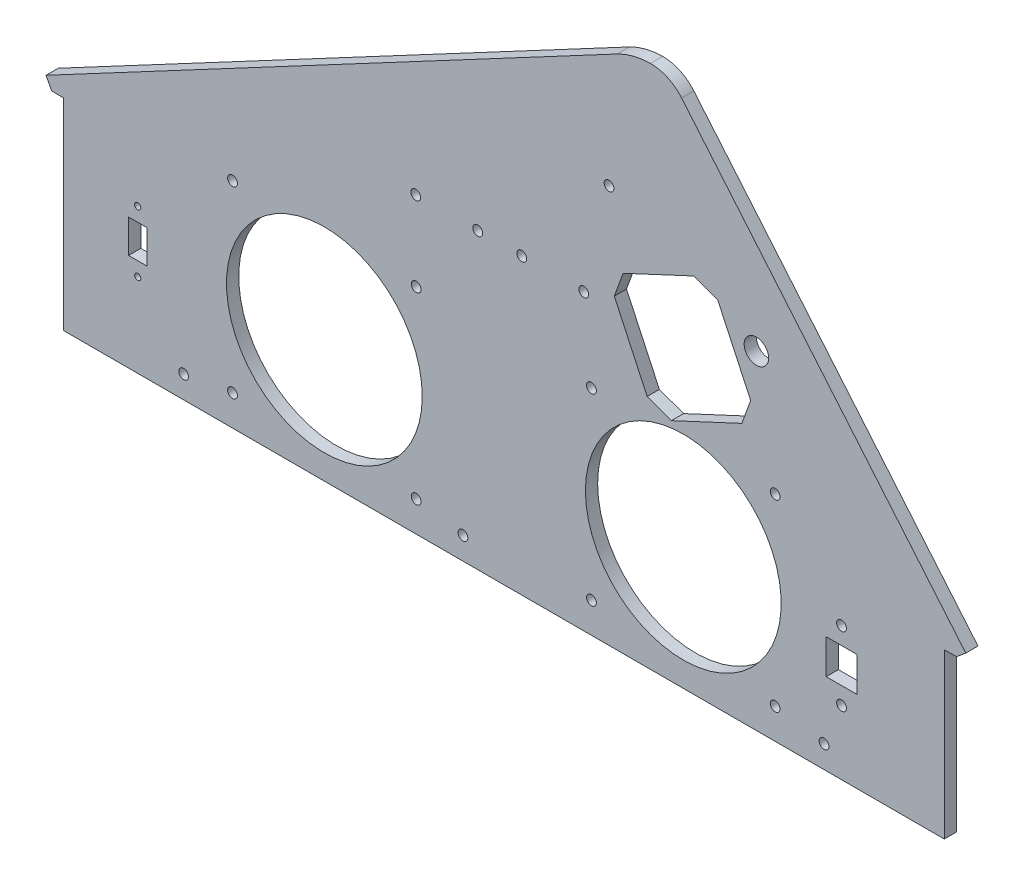
from build123d import *

# Parameters (mm, degrees)
BOSS_EXTRUDE1_DEPTH = 4.7625
SKETCH2_R           = 1.905
CUT_EXTRUDE1_DEPTH  = 407.344943003
SKETCH3_R           = 38.1
SKETCH3_R_2         = 1.905
CUT_EXTRUDE2_DEPTH  = 407.344943003
SKETCH4_R           = 1.905
SKETCH4_W           = 11.938
SKETCH4_H           = 13.462
CUT_EXTRUDE3_DEPTH  = 407.344943003
SKETCH5_R           = 1.905
CUT_EXTRUDE4_DEPTH  = 407.344943003
SKETCH6_R           = 1.1938
SKETCH6_W           = 7.112
SKETCH6_H           = 12.954
CUT_EXTRUDE5_DEPTH  = 407.344943003
SKETCH7_W           = 1.346153846
SKETCH7_H           = 0.358974359
CUT_EXTRUDE6_DEPTH  = 1.016
CUT_EXTRUDE7_DEPTH  = 407.344943141
SKETCH9_R           = 4.7625
CUT_EXTRUDE13_DEPTH = 579.055475551


with BuildPart() as part:
    # Sketch1 → Boss-Extrude1 (new body)
    with BuildSketch(Plane.XY):
        with BuildLine():
            Line((342.9, 0), (342.9, 63.846084025))
            Line((342.9, 63.846084025), (347.6625, 63.846084025))
            Line((347.6625, 63.846084025), (351.246350093, 66.853291317))
            Line((351.246350093, 66.853291317), (240.642270942, 198.6661))
            ThreePointArc((240.642270942, 198.6661), (235.199196057, 202.821062746), (228.502863126, 204.252811641))
            ThreePointArc((228.502863126, 204.252811641), (221.829642318, 203.38166914), (215.553659607, 200.9521))
            Line((215.553659607, 200.9521), (-6.746192899, 82.628723888))
            Line((-6.746192899, 82.628723888), (-4.5085, 78.424661955))
            Line((-4.5085, 78.424661955), (0, 78.424661955))
            Line((0, 78.424661955), (0, 0))
            Line((0, 0), (342.9, 0))
        make_face()
    extrude(amount=BOSS_EXTRUDE1_DEPTH)

    # Sketch2 → Cut-Extrude1 (cut, through all)
    with BuildSketch(Plane.XY.offset(4.7625)):
        with Locations((46.8249, 8.73125)):
            Circle(SKETCH2_R)
        with Locations((296.0751, 8.73125)):
            Circle(SKETCH2_R)
        with Locations((155.5496, 8.73125)):
            Circle(SKETCH2_R)
        with Locations((212.41385, 154.94)):
            Circle(SKETCH2_R)
    extrude(amount=-CUT_EXTRUDE1_DEPTH, mode=Mode.SUBTRACT)

    # Sketch3 → Cut-Extrude2 (cut, through all)
    with BuildSketch(Plane.XY.offset(4.7625)):
        with Locations((101.6, 47.625)):
            Circle(SKETCH3_R)
        with Locations((137.35, 83.375)):
            Circle(SKETCH3_R_2)
        with Locations((65.85, 83.375)):
            Circle(SKETCH3_R_2)
        with Locations((65.85, 11.875)):
            Circle(SKETCH3_R_2)
        with Locations((137.35, 11.875)):
            Circle(SKETCH3_R_2)
        with Locations((205.55, 11.875)):
            Circle(SKETCH3_R_2)
        with Locations((277.05, 11.875)):
            Circle(SKETCH3_R_2)
        with Locations((277.05, 83.375)):
            Circle(SKETCH3_R_2)
        with Locations((205.55, 83.375)):
            Circle(SKETCH3_R_2)
        with Locations((241.3, 47.625)):
            Circle(SKETCH3_R)
    extrude(amount=-CUT_EXTRUDE2_DEPTH, mode=Mode.SUBTRACT)

    # Sketch4 → Cut-Extrude3 (cut, through all)
    with BuildSketch(Plane.XY.offset(4.7625)):
        with Locations((302.895, 51.943)):
            Circle(SKETCH4_R)
        with Locations((302.895, 25.019)):
            Circle(SKETCH4_R)
        with Locations((302.895, 38.481)):
            Rectangle(SKETCH4_W, SKETCH4_H)
    extrude(amount=-CUT_EXTRUDE3_DEPTH, mode=Mode.SUBTRACT)

    # Sketch5 → Cut-Extrude4 (cut, through all)
    with BuildSketch(Plane.XY.offset(4.7625)):
        with Locations((137.16, 114.3)):
            Circle(SKETCH5_R)
        with Locations((161.29, 114.3)):
            Circle(SKETCH5_R)
        with Locations((178.435, 114.3)):
            Circle(SKETCH5_R)
        with Locations((202.565, 114.3)):
            Circle(SKETCH5_R)
    extrude(amount=-CUT_EXTRUDE4_DEPTH, mode=Mode.SUBTRACT)

    # Sketch6 → Cut-Extrude5 (cut, through all)
    with BuildSketch(Plane.XY.offset(4.7625)):
        with Locations((28.956, 56.35)):
            Circle(SKETCH6_R)
        with Locations((28.956, 32.55)):
            Circle(SKETCH6_R)
        with Locations((28.956, 44.45)):
            Rectangle(SKETCH6_W, SKETCH6_H)
    extrude(amount=-CUT_EXTRUDE5_DEPTH, mode=Mode.SUBTRACT)

    # Sketch7 → Cut-Extrude6 (cut)
    # profile 1 of 9: a face of its own
    with BuildSketch(Plane(origin=(0, 0, 0), x_dir=(-1, 0, 0), z_dir=(0, 0, -1))):
        with BuildLine():
            Line((-20.262820513, 9.93974359), (-20.020933494, 9.749739583))
            Line((-20.020933494, 9.749739583), (-20.945713141, 8.335576923))
            add(Edge.make_bspline(
                [(-20.945713141, 8.335576923), (-20.884142864, 8.345390784), (-20.764043077, 8.364533829), (-20.642477179, 8.367691774), (-20.583233173, 8.369230769)],
                knots=[0, 0, 0, 0, 1.025318673, 2, 2, 2, 2], degree=3))
            add(Edge.make_bspline(
                [(-20.583233173, 8.369230769), (-20.547660677, 8.368274658), (-20.477637276, 8.36639258), (-20.374830474, 8.351908729), (-20.276041538, 8.329083617), (-20.181679926, 8.295811362), (-20.091406944, 8.253309007), (-20.004704548, 8.202370137), (-19.923202538, 8.140364457), (-19.845851359, 8.071099501), (-19.775624261, 7.994382516), (-19.713448206, 7.91298118), (-19.661221414, 7.826980299), (-19.618847492, 7.736423433), (-19.585942614, 7.641450173), (-19.561954969, 7.542182034), (-19.547775376, 7.438550562), (-19.545849885, 7.368072387), (-19.544871795, 7.332271635)],
                knots=[0, 0, 0, 0, 1.04369286, 2.054478336, 3.041073146, 4.015093852, 4.984733326, 5.965804835, 6.960378782, 7.985147595, 9.009457201, 10.008161701, 10.986880575, 11.956520048, 12.937015923, 13.931873656, 14.949455224, 16, 16, 16, 16], degree=3))
            add(Edge.make_bspline(
                [(-19.544871795, 7.332271635), (-19.5462949, 7.283291931), (-19.549095233, 7.186911465), (-19.576999029, 7.046534758), (-19.620358674, 6.912802243), (-19.682336203, 6.787849071), (-19.759318586, 6.671846502), (-19.853196178, 6.569061036), (-19.960639667, 6.477390999), (-20.082126465, 6.40073438), (-20.212869429, 6.338131329), (-20.350221426, 6.293166087), (-20.492848573, 6.265482617), (-20.589653181, 6.262012015), (-20.638621795, 6.26025641)],
                knots=[0, 0, 0, 0, 1.031375318, 2.029502543, 3.004789286, 3.987476834, 4.960371455, 5.9300674, 6.912260825, 7.929083631, 8.949397511, 9.960523116, 10.96833055, 12, 12, 12, 12], degree=3))
            add(Edge.make_bspline(
                [(-20.638621795, 6.26025641), (-20.685718496, 6.261784616), (-20.779008814, 6.264811724), (-20.916241608, 6.291777662), (-21.048104625, 6.335484765), (-21.173674006, 6.395699043), (-21.289994619, 6.471756926), (-21.394060255, 6.563319205), (-21.48535203, 6.66842867), (-21.561326651, 6.787069018), (-21.621585383, 6.914558975), (-21.666775308, 7.047496132), (-21.693171551, 7.185396113), (-21.696860108, 7.278877252), (-21.698717949, 7.325961538)],
                knots=[0, 0, 0, 0, 1.012016664, 2.004627821, 2.994792927, 3.992885782, 4.990978636, 5.973936114, 6.964471063, 7.975201453, 8.993600317, 9.990122807, 10.98767138, 12, 12, 12, 12], degree=3))
            add(Edge.make_bspline(
                [(-21.698717949, 7.325961538), (-21.697536504, 7.362006122), (-21.695124219, 7.435602274), (-21.678280828, 7.547066302), (-21.651216034, 7.661117383), (-21.620905787, 7.757871577), (-21.588880177, 7.837133099), (-21.562227638, 7.90103659), (-21.529053642, 7.966797663), (-21.49368026, 8.036671299), (-21.452923391, 8.108856731), (-21.408607742, 8.184560401), (-21.359508091, 8.262578329), (-21.325087928, 8.315522524), (-21.307491987, 8.342588141)],
                knots=[0, 0, 0, 0, 1.173818275, 2.396712641, 3.66331629, 4.989737886, 5.693666774, 6.447286557, 7.243889047, 8.091586357, 8.998013824, 9.943181721, 10.948533338, 12, 12, 12, 12], degree=3))
            Line((-21.307491987, 8.342588141), (-20.262820513, 9.93974359))
        make_face()
        with BuildLine():
            add(Edge.make_bspline(
                [(-20.649138622, 8.01025641), (-20.675800867, 8.009478367), (-20.727879976, 8.007958621), (-20.804287391, 7.999133369), (-20.876600642, 7.982514304), (-20.945777776, 7.961347972), (-21.010525479, 7.932244912), (-21.071314319, 7.896893113), (-21.12837937, 7.855271935), (-21.181122922, 7.807971024), (-21.228942586, 7.756182991), (-21.270123716, 7.700713469), (-21.305646116, 7.642899266), (-21.334527935, 7.582257323), (-21.357018011, 7.518810824), (-21.373286262, 7.452851574), (-21.382340013, 7.383937268), (-21.383846245, 7.337204766), (-21.384615385, 7.313341346)],
                knots=[0, 0, 0, 0, 1.129588631, 2.206414736, 3.251139165, 4.268635594, 5.265702196, 6.250456724, 7.242448911, 8.251968645, 9.246821453, 10.222880186, 11.173611482, 12.116736599, 13.062300278, 14.020270554, 14.989073742, 16, 16, 16, 16], degree=3))
            add(Edge.make_bspline(
                [(-21.384615385, 7.313341346), (-21.383989023, 7.289691366), (-21.382760822, 7.243317277), (-21.371608502, 7.174978097), (-21.354573419, 7.109213189), (-21.329233023, 7.04636159), (-21.299006135, 6.985465272), (-21.259100811, 6.928729986), (-21.214884025, 6.872709916), (-21.162030092, 6.821708445), (-21.105306729, 6.774251821), (-21.044705526, 6.732771567), (-20.981545566, 6.697285394), (-20.914974144, 6.669474296), (-20.84593576, 6.646650009), (-20.773855206, 6.63058853), (-20.698682351, 6.621508004), (-20.647760413, 6.61999981), (-20.621794872, 6.619230769)],
                knots=[0, 0, 0, 0, 0.989467248, 1.94019797, 2.891935182, 3.827694429, 4.772920941, 5.730924762, 6.725747692, 7.756678648, 8.79901574, 9.819492441, 10.826891316, 11.826466727, 12.835195252, 13.867842842, 14.912794438, 16, 16, 16, 16], degree=3))
            add(Edge.make_bspline(
                [(-20.621794872, 6.619230769), (-20.595829373, 6.619999871), (-20.544907519, 6.621508182), (-20.469734058, 6.630587851), (-20.39765574, 6.646652499), (-20.328609231, 6.66946527), (-20.2620678, 6.697318879), (-20.198963079, 6.732550799), (-20.138934985, 6.774506917), (-20.082174386, 6.821627345), (-20.029540447, 6.873000197), (-19.984263168, 6.928229919), (-19.945579935, 6.985923815), (-19.914145748, 7.046121704), (-19.889084457, 7.109251192), (-19.87196299, 7.174967916), (-19.860833701, 7.243319942), (-19.859602334, 7.289692266), (-19.858974359, 7.313341346)],
                knots=[0, 0, 0, 0, 1.087397944, 2.132534446, 3.165364764, 4.174271784, 5.174024072, 6.181601208, 7.194203697, 8.236725232, 9.267838612, 10.269026844, 11.221737037, 12.171628256, 13.107553087, 14.05945871, 15.010357665, 16, 16, 16, 16], degree=3))
            add(Edge.make_bspline(
                [(-19.858974359, 7.313341346), (-19.859524652, 7.337235897), (-19.860604698, 7.38413313), (-19.872820647, 7.452820748), (-19.889763021, 7.519145954), (-19.915346051, 7.582691903), (-19.948582596, 7.64320783), (-19.989066003, 7.700999431), (-20.035898573, 7.756509779), (-20.089996113, 7.808072587), (-20.148886347, 7.855219665), (-20.211501932, 7.896839221), (-20.277009906, 7.931964198), (-20.345343848, 7.9612713), (-20.417286731, 7.982420774), (-20.49167707, 7.999074017), (-20.569466313, 8.007936035), (-20.622242921, 8.0094731), (-20.649138622, 8.01025641)],
                knots=[0, 0, 0, 0, 0.978206639, 1.919901502, 2.851605144, 3.780102724, 4.718870031, 5.675451981, 6.667674623, 7.690630536, 8.733308323, 9.756129687, 10.767539656, 11.776269907, 12.797430371, 13.836405707, 14.897401972, 16, 16, 16, 16], degree=3))
        make_face(mode=Mode.SUBTRACT)
    # profile 2 of 9: a face of its own
    with BuildSketch(Plane(origin=(0, 0, 0), x_dir=(-1, 0, 0), z_dir=(0, 0, -1))):
        with BuildLine():
            add(Edge.make_bspline(
                [(-24.570512821, 8.098597756), (-24.570184802, 8.154695144), (-24.569547622, 8.263665128), (-24.562459201, 8.42244977), (-24.550683859, 8.571410059), (-24.534546486, 8.710553125), (-24.514908506, 8.83991489), (-24.488693019, 8.959149647), (-24.458880217, 9.068809254), (-24.424327771, 9.169251302), (-24.385339982, 9.261829005), (-24.342905721, 9.348254207), (-24.295340927, 9.428396139), (-24.245364014, 9.503533929), (-24.190951942, 9.572437624), (-24.133653152, 9.636080287), (-24.071231276, 9.692991037), (-24.005808267, 9.744837339), (-23.936791803, 9.790286811), (-23.866149137, 9.83031955), (-23.793394031, 9.864519417), (-23.718327848, 9.891409853), (-23.64162529, 9.9136207), (-23.563018223, 9.928809647), (-23.482376859, 9.938366556), (-23.427945425, 9.939280224), (-23.400340545, 9.93974359)],
                knots=[0, 0, 0, 0, 1.646270934, 3.197905019, 4.663502075, 6.030701355, 7.308322542, 8.50163776, 9.611534131, 10.641858119, 11.616356847, 12.558055219, 13.465016945, 14.349605745, 15.204443733, 16.039544428, 16.859896111, 17.680448484, 18.487036065, 19.28249412, 20.06191084, 20.843045899, 21.620316918, 22.403196591, 23.190181807, 24, 24, 24, 24], degree=3))
            add(Edge.make_bspline(
                [(-23.400340545, 9.93974359), (-23.372505066, 9.939255775), (-23.317149057, 9.938285664), (-23.235308682, 9.928961721), (-23.155359001, 9.913490598), (-23.077640862, 9.891569623), (-23.001515875, 9.864373947), (-22.927579468, 9.83028683), (-22.855372386, 9.790607962), (-22.786042099, 9.743984085), (-22.718827483, 9.692001809), (-22.65537952, 9.63323914), (-22.595692434, 9.568289421), (-22.539017129, 9.497847557), (-22.486961532, 9.420562472), (-22.4373881, 9.337778362), (-22.393016064, 9.248047497), (-22.350281388, 9.15286703), (-22.313394402, 9.049603371), (-22.280128156, 8.93883861), (-22.253249188, 8.819264423), (-22.230859916, 8.691508178), (-22.21351502, 8.555100695), (-22.200882377, 8.410334379), (-22.194209292, 8.257113989), (-22.192952591, 8.15235614), (-22.192307692, 8.098597756)],
                knots=[0, 0, 0, 0, 0.810914788, 1.612654377, 2.396697861, 3.181598691, 3.963628158, 4.749916497, 5.551656086, 6.361998678, 7.18212741, 8.025565596, 8.878627764, 9.750805457, 10.657531673, 11.591944965, 12.560506719, 13.57287815, 14.630710178, 15.753379473, 16.941251878, 18.199788006, 19.531962791, 20.947069417, 22.433333509, 24, 24, 24, 24], degree=3))
            add(Edge.make_bspline(
                [(-22.192307692, 8.098597756), (-22.192959277, 8.045073848), (-22.194228863, 7.940784697), (-22.20080757, 7.788253721), (-22.213766201, 7.644255678), (-22.229976189, 7.508445216), (-22.252427152, 7.381387597), (-22.280032318, 7.262643148), (-22.310682641, 7.151699077), (-22.348517435, 7.049464265), (-22.389928146, 6.954512542), (-22.434983342, 6.865845394), (-22.483253168, 6.782679101), (-22.535841913, 6.705679354), (-22.591895326, 6.634300697), (-22.652613115, 6.569803074), (-22.7162837, 6.510632402), (-22.783696116, 6.457980775), (-22.854107667, 6.41189597), (-22.926066744, 6.37068212), (-23.000850127, 6.337449425), (-23.07676308, 6.308914384), (-23.154891446, 6.287113932), (-23.235137837, 6.272040077), (-23.317094073, 6.261468228), (-23.372495638, 6.260661748), (-23.400340545, 6.26025641)],
                knots=[0, 0, 0, 0, 1.561518951, 3.042555995, 4.452378317, 5.7783523, 7.031515105, 8.214008947, 9.334062868, 10.386615937, 11.391082383, 12.354592575, 13.286541444, 14.194233754, 15.072674879, 15.931287219, 16.775624067, 17.606195743, 18.42308326, 19.229000347, 20.022332153, 20.807536673, 21.593273796, 22.3848459, 23.188221202, 24, 24, 24, 24], degree=3))
            add(Edge.make_bspline(
                [(-23.400340545, 6.26025641), (-23.427944659, 6.260722766), (-23.482374584, 6.261642328), (-23.563027009, 6.271156059), (-23.641309453, 6.286451562), (-23.717608207, 6.307868166), (-23.792314722, 6.334083003), (-23.864411008, 6.368236686), (-23.934698692, 6.407570755), (-24.002990248, 6.452366177), (-24.068002409, 6.50368786), (-24.130101014, 6.560452149), (-24.187726033, 6.62407556), (-24.241360129, 6.693553483), (-24.292334217, 6.768246725), (-24.339223591, 6.849175098), (-24.382594445, 6.936017709), (-24.422237935, 7.02933562), (-24.457386599, 7.130490547), (-24.488434307, 7.240639726), (-24.512948464, 7.360755362), (-24.53393142, 7.489872729), (-24.550855803, 7.628546659), (-24.562410128, 7.776852438), (-24.569551443, 7.934697647), (-24.570186514, 8.042967421), (-24.570512821, 8.098597756)],
                knots=[0, 0, 0, 0, 0.810891512, 1.598919785, 2.382837074, 3.152667961, 3.926044502, 4.706494248, 5.493654104, 6.291793342, 7.103789334, 7.925228297, 8.761435821, 9.622817696, 10.50288917, 11.416980706, 12.369136599, 13.353924996, 14.394355917, 15.514179734, 16.714354668, 17.994756427, 19.357759367, 20.818452758, 22.365282078, 24, 24, 24, 24], degree=3))
        make_face()
        with BuildLine():
            add(Edge.make_bspline(
                [(-24.256410256, 8.1), (-24.256290809, 8.053251301), (-24.256058986, 7.962521256), (-24.250002785, 7.830677995), (-24.241752553, 7.707707667), (-24.231111256, 7.59345413), (-24.215308308, 7.488304118), (-24.19760152, 7.391534435), (-24.17605343, 7.303657197), (-24.150558412, 7.224069387), (-24.121519316, 7.151420318), (-24.089813452, 7.083819103), (-24.055752729, 7.020467167), (-24.017633578, 6.961933558), (-23.976118515, 6.908027394), (-23.932145256, 6.857794562), (-23.884072672, 6.812997581), (-23.817568929, 6.759270726), (-23.729772455, 6.703751592), (-23.619152, 6.655405502), (-23.505483549, 6.625023046), (-23.428332299, 6.62115929), (-23.389823718, 6.619230769)],
                knots=[0, 0, 0, 0, 1.459021318, 2.831673884, 4.118529203, 5.306027144, 6.411944654, 7.436330062, 8.375795394, 9.233974572, 10.042671642, 10.816086306, 11.563610507, 12.285937304, 12.993564865, 13.685989202, 14.367179055, 15.041617293, 16.353048772, 17.594441528, 18.799311195, 20, 20, 20, 20], degree=3))
            add(Edge.make_bspline(
                [(-23.389823718, 6.619230769), (-23.351066046, 6.62082855), (-23.273630723, 6.624020813), (-23.160496928, 6.65481955), (-23.050666658, 6.70128909), (-22.964594718, 6.756236595), (-22.899112174, 6.808564925), (-22.852195184, 6.853179573), (-22.809133136, 6.90313544), (-22.768291061, 6.957034736), (-22.730831985, 7.01590722), (-22.696768847, 7.079469796), (-22.6656855, 7.147898973), (-22.647976454, 7.195668713), (-22.638922276, 7.220092147)],
                knots=[0, 0, 0, 0, 1.353760809, 2.704726607, 4.075137775, 5.516104923, 6.260822281, 7.007110065, 7.778089737, 8.566572457, 9.372053459, 10.217411131, 11.088608312, 12, 12, 12, 12], degree=3))
            add(Edge.make_bspline(
                [(-22.638922276, 7.220092147), (-22.628370508, 7.251321887), (-22.606945894, 7.314731651), (-22.57933412, 7.413095303), (-22.557588721, 7.516298067), (-22.538025355, 7.623723184), (-22.524672299, 7.736162885), (-22.513924486, 7.853269269), (-22.507593799, 7.975130631), (-22.506809048, 8.057925622), (-22.506410256, 8.1)],
                knots=[0, 0, 0, 0, 0.884706709, 1.796334032, 2.740027952, 3.714592787, 4.726048262, 5.777819803, 6.87074269, 8, 8, 8, 8], degree=3))
            add(Edge.make_bspline(
                [(-22.506410256, 8.1), (-22.506960446, 8.142067573), (-22.508036733, 8.224360737), (-22.512150721, 8.344878918), (-22.522774296, 8.459346679), (-22.534573414, 8.568257152), (-22.551970636, 8.671007454), (-22.570728442, 8.768457759), (-22.595929655, 8.859400784), (-22.62284943, 8.945260366), (-22.653659825, 9.025061021), (-22.687575559, 9.099174807), (-22.723797318, 9.167959532), (-22.763139559, 9.231226473), (-22.805135242, 9.289259016), (-22.850892791, 9.340893611), (-22.898597164, 9.387730579), (-22.96541435, 9.441193148), (-23.052888639, 9.495704843), (-23.161734287, 9.545870603), (-23.275004931, 9.574678896), (-23.351578385, 9.578740583), (-23.389823718, 9.580769231)],
                knots=[0, 0, 0, 0, 1.31362396, 2.569729283, 3.763502607, 4.902122613, 5.988968491, 7.01645872, 7.998833611, 8.933434873, 9.825090667, 10.667526885, 11.477055099, 12.250526234, 12.991942729, 13.710640831, 14.402115721, 15.076753259, 16.378508321, 17.609869233, 18.806226677, 20, 20, 20, 20], degree=3))
            add(Edge.make_bspline(
                [(-23.389823718, 9.580769231), (-23.42853431, 9.578737784), (-23.506026016, 9.57467119), (-23.62047397, 9.545977936), (-23.730178322, 9.49596497), (-23.817421297, 9.441012598), (-23.884285083, 9.388674287), (-23.931367777, 9.343287833), (-23.975513949, 9.293641578), (-24.016181649, 9.239239663), (-24.054270932, 9.180774296), (-24.089251945, 9.117785531), (-24.120769274, 9.049954167), (-24.149853811, 8.977337732), (-24.175426599, 8.897756787), (-24.196520562, 8.809987794), (-24.216007615, 8.713525902), (-24.229802884, 8.607806394), (-24.24206664, 8.49352424), (-24.249947988, 8.370246922), (-24.256079245, 8.238182542), (-24.256297709, 8.146983383), (-24.256410256, 8.1)],
                knots=[0, 0, 0, 0, 1.207732386, 2.417664972, 3.655092373, 4.956220595, 5.625982001, 6.301752483, 6.994047911, 7.697131622, 8.419323945, 9.170223765, 9.943494443, 10.752040957, 11.610060368, 12.549350801, 13.567764191, 14.679664412, 15.874934091, 17.154273443, 18.533957287, 20, 20, 20, 20], degree=3))
        make_face(mode=Mode.SUBTRACT)
    # profile 3 of 9: a face of its own
    with BuildSketch(Plane(origin=(0, 0, 0), x_dir=(-1, 0, 0), z_dir=(0, 0, -1))):
        with BuildLine():
            Line((-25.647435897, 9.93974359), (-25.405548878, 9.749739583))
            Line((-25.405548878, 9.749739583), (-26.330328526, 8.335576923))
            add(Edge.make_bspline(
                [(-26.330328526, 8.335576923), (-26.268758249, 8.345390784), (-26.148658462, 8.364533829), (-26.027092563, 8.367691774), (-25.967848558, 8.369230769)],
                knots=[0, 0, 0, 0, 1.025318673, 2, 2, 2, 2], degree=3))
            add(Edge.make_bspline(
                [(-25.967848558, 8.369230769), (-25.932276061, 8.368274658), (-25.862252661, 8.36639258), (-25.759445859, 8.351908729), (-25.660656923, 8.329083617), (-25.56629531, 8.295811362), (-25.476022329, 8.253309007), (-25.389319933, 8.202370137), (-25.307817922, 8.140364457), (-25.230466743, 8.071099501), (-25.160239646, 7.994382516), (-25.09806359, 7.91298118), (-25.045836799, 7.826980299), (-25.003462877, 7.736423433), (-24.970557998, 7.641450173), (-24.946570353, 7.542182034), (-24.93239076, 7.438550562), (-24.93046527, 7.368072387), (-24.929487179, 7.332271635)],
                knots=[0, 0, 0, 0, 1.04369286, 2.054478336, 3.041073146, 4.015093852, 4.984733326, 5.965804835, 6.960378782, 7.985147595, 9.009457201, 10.008161701, 10.986880575, 11.956520048, 12.937015923, 13.931873656, 14.949455224, 16, 16, 16, 16], degree=3))
            add(Edge.make_bspline(
                [(-24.929487179, 7.332271635), (-24.930910284, 7.283291931), (-24.933710618, 7.186911465), (-24.961614414, 7.046534758), (-25.004974059, 6.912802243), (-25.066951587, 6.787849071), (-25.14393397, 6.671846502), (-25.237811563, 6.569061036), (-25.345255051, 6.477390999), (-25.466741849, 6.40073438), (-25.597484813, 6.338131329), (-25.734836811, 6.293166087), (-25.877463957, 6.265482617), (-25.974268565, 6.262012015), (-26.023237179, 6.26025641)],
                knots=[0, 0, 0, 0, 1.031375318, 2.029502543, 3.004789286, 3.987476834, 4.960371455, 5.9300674, 6.912260825, 7.929083631, 8.949397511, 9.960523116, 10.96833055, 12, 12, 12, 12], degree=3))
            add(Edge.make_bspline(
                [(-26.023237179, 6.26025641), (-26.07033388, 6.261784616), (-26.163624198, 6.264811724), (-26.300856992, 6.291777662), (-26.43272001, 6.335484765), (-26.558289391, 6.395699043), (-26.674610004, 6.471756926), (-26.77867564, 6.563319205), (-26.869967415, 6.66842867), (-26.945942035, 6.787069018), (-27.006200767, 6.914558975), (-27.051390693, 7.047496132), (-27.077786936, 7.185396113), (-27.081475493, 7.278877252), (-27.083333333, 7.325961538)],
                knots=[0, 0, 0, 0, 1.012016664, 2.004627821, 2.994792927, 3.992885782, 4.990978636, 5.973936114, 6.964471063, 7.975201453, 8.993600317, 9.990122807, 10.98767138, 12, 12, 12, 12], degree=3))
            add(Edge.make_bspline(
                [(-27.083333333, 7.325961538), (-27.082151888, 7.362006122), (-27.079739603, 7.435602274), (-27.062896213, 7.547066302), (-27.035831418, 7.661117383), (-27.005521172, 7.757871577), (-26.973495562, 7.837133099), (-26.946843022, 7.90103659), (-26.913669026, 7.966797663), (-26.878295645, 8.036671299), (-26.837538776, 8.108856731), (-26.793223127, 8.184560401), (-26.744123476, 8.262578329), (-26.709703313, 8.315522524), (-26.692107372, 8.342588141)],
                knots=[0, 0, 0, 0, 1.173818275, 2.396712641, 3.66331629, 4.989737886, 5.693666774, 6.447286557, 7.243889047, 8.091586357, 8.998013824, 9.943181721, 10.948533338, 12, 12, 12, 12], degree=3))
            Line((-26.692107372, 8.342588141), (-25.647435897, 9.93974359))
        make_face()
        with BuildLine():
            add(Edge.make_bspline(
                [(-26.033754006, 8.01025641), (-26.060416251, 8.009478367), (-26.112495361, 8.007958621), (-26.188902775, 7.999133369), (-26.261216027, 7.982514304), (-26.33039316, 7.961347972), (-26.395140863, 7.932244912), (-26.455929703, 7.896893113), (-26.512994755, 7.855271935), (-26.565738307, 7.807971024), (-26.61355797, 7.756182991), (-26.654739101, 7.700713469), (-26.690261501, 7.642899266), (-26.71914332, 7.582257323), (-26.741633396, 7.518810824), (-26.757901647, 7.452851574), (-26.766955398, 7.383937268), (-26.768461629, 7.337204766), (-26.769230769, 7.313341346)],
                knots=[0, 0, 0, 0, 1.129588631, 2.206414736, 3.251139165, 4.268635594, 5.265702196, 6.250456724, 7.242448911, 8.251968645, 9.246821453, 10.222880186, 11.173611482, 12.116736599, 13.062300278, 14.020270554, 14.989073742, 16, 16, 16, 16], degree=3))
            add(Edge.make_bspline(
                [(-26.769230769, 7.313341346), (-26.768604408, 7.289691366), (-26.767376206, 7.243317277), (-26.756223886, 7.174978097), (-26.739188804, 7.109213189), (-26.713848408, 7.04636159), (-26.68362152, 6.985465272), (-26.643716196, 6.928729986), (-26.59949941, 6.872709916), (-26.546645476, 6.821708445), (-26.489922113, 6.774251821), (-26.429320911, 6.732771567), (-26.366160951, 6.697285394), (-26.299589529, 6.669474296), (-26.230551145, 6.646650009), (-26.158470591, 6.63058853), (-26.083297735, 6.621508004), (-26.032375797, 6.61999981), (-26.006410256, 6.619230769)],
                knots=[0, 0, 0, 0, 0.989467248, 1.94019797, 2.891935182, 3.827694429, 4.772920941, 5.730924762, 6.725747692, 7.756678648, 8.79901574, 9.819492441, 10.826891316, 11.826466727, 12.835195252, 13.867842842, 14.912794438, 16, 16, 16, 16], degree=3))
            add(Edge.make_bspline(
                [(-26.006410256, 6.619230769), (-25.980444758, 6.619999871), (-25.929522903, 6.621508182), (-25.854349443, 6.630587851), (-25.782271124, 6.646652499), (-25.713224616, 6.66946527), (-25.646683185, 6.697318879), (-25.583578463, 6.732550799), (-25.52355037, 6.774506917), (-25.46678977, 6.821627345), (-25.414155832, 6.873000197), (-25.368878553, 6.928229919), (-25.33019532, 6.985923815), (-25.298761133, 7.046121704), (-25.273699841, 7.109251192), (-25.256578374, 7.174967916), (-25.245449085, 7.243319942), (-25.244217719, 7.289692266), (-25.243589744, 7.313341346)],
                knots=[0, 0, 0, 0, 1.087397944, 2.132534446, 3.165364764, 4.174271784, 5.174024072, 6.181601208, 7.194203697, 8.236725232, 9.267838612, 10.269026844, 11.221737037, 12.171628256, 13.107553087, 14.05945871, 15.010357665, 16, 16, 16, 16], degree=3))
            add(Edge.make_bspline(
                [(-25.243589744, 7.313341346), (-25.244140037, 7.337235897), (-25.245220083, 7.38413313), (-25.257436031, 7.452820748), (-25.274378405, 7.519145954), (-25.299961436, 7.582691903), (-25.333197981, 7.64320783), (-25.373681388, 7.700999431), (-25.420513958, 7.756509779), (-25.474611498, 7.808072587), (-25.533501732, 7.855219665), (-25.596117317, 7.896839221), (-25.661625291, 7.931964198), (-25.729959233, 7.9612713), (-25.801902116, 7.982420774), (-25.876292455, 7.999074017), (-25.954081698, 8.007936035), (-26.006858306, 8.0094731), (-26.033754006, 8.01025641)],
                knots=[0, 0, 0, 0, 0.978206639, 1.919901502, 2.851605144, 3.780102724, 4.718870031, 5.675451981, 6.667674623, 7.690630536, 8.733308323, 9.756129687, 10.767539656, 11.776269907, 12.797430371, 13.836405707, 14.897401972, 16, 16, 16, 16], degree=3))
        make_face(mode=Mode.SUBTRACT)
    # profile 4 of 9: a face of its own
    with BuildSketch(Plane(origin=(0, 0, 0), x_dir=(-1, 0, 0), z_dir=(0, 0, -1))):
        with Locations((-28.205128205, 7.696153847)):
            Rectangle(SKETCH7_W, SKETCH7_H)
    # profile 5 of 9: a face of its own
    with BuildSketch(Plane(origin=(0, 0, 0), x_dir=(-1, 0, 0), z_dir=(0, 0, -1))):
        with BuildLine():
            Line((-31.435897436, 9.85), (-30.749499199, 9.85))
            add(Edge.make_bspline(
                [(-30.749499199, 9.85), (-30.702288293, 9.849948104), (-30.6118301, 9.849848668), (-30.482115044, 9.846833922), (-30.364305312, 9.84280723), (-30.258654931, 9.837225337), (-30.164838833, 9.830628747), (-30.083281534, 9.821376708), (-30.013341978, 9.811716412), (-29.971435528, 9.801895005), (-29.952323718, 9.797415865)],
                knots=[0, 0, 0, 0, 1.415646017, 2.712440637, 3.8905458, 4.950247383, 5.884950622, 6.709939814, 7.411656543, 8, 8, 8, 8], degree=3))
            add(Edge.make_bspline(
                [(-29.952323718, 9.797415865), (-29.928130184, 9.790793916), (-29.880313207, 9.777706054), (-29.811412164, 9.75149233), (-29.745858318, 9.720410165), (-29.68342676, 9.684986225), (-29.624884677, 9.643700661), (-29.569358636, 9.598227043), (-29.517338656, 9.547515475), (-29.469117264, 9.492134735), (-29.424832466, 9.433014525), (-29.386702783, 9.369272295), (-29.354775556, 9.301980992), (-29.327392285, 9.231187421), (-29.30768383, 9.156297097), (-29.292836931, 9.077830385), (-29.283413303, 8.995795695), (-29.282510741, 8.939735827), (-29.282051282, 8.911197917)],
                knots=[0, 0, 0, 0, 0.999701418, 1.975846123, 2.934577507, 3.890451536, 4.834027766, 5.787354733, 6.749476667, 7.726910423, 8.712836071, 9.690891519, 10.682875813, 11.679750201, 12.712814741, 13.765529915, 14.8625177, 16, 16, 16, 16], degree=3))
            add(Edge.make_bspline(
                [(-29.282051282, 8.911197917), (-29.282472707, 8.88242014), (-29.283297253, 8.826114476), (-29.293193538, 8.743741688), (-29.30652373, 8.665023298), (-29.327020782, 8.590133847), (-29.353866455, 8.519518077), (-29.385358508, 8.452096845), (-29.423342038, 8.389017173), (-29.466986868, 8.330050055), (-29.515538462, 8.275140143), (-29.568791401, 8.224685348), (-29.626530693, 8.17898101), (-29.688572841, 8.137924666), (-29.75552269, 8.102468387), (-29.826364844, 8.070711082), (-29.90171506, 8.044040021), (-29.953857574, 8.03000996), (-29.98036859, 8.022876603)],
                knots=[0, 0, 0, 0, 1.121902311, 2.195077645, 3.232258892, 4.234102512, 5.217864754, 6.176164875, 7.132989551, 8.084763148, 9.034132444, 9.988522005, 10.94243251, 11.903244335, 12.886203696, 13.894208494, 14.929344452, 16, 16, 16, 16], degree=3))
            add(Edge.make_bspline(
                [(-29.98036859, 8.022876603), (-30.002295924, 8.018213621), (-30.050350951, 8.007994427), (-30.129493673, 7.99658597), (-30.221639059, 7.98684837), (-30.326661339, 7.979547232), (-30.444466244, 7.973296864), (-30.575117501, 7.96832877), (-30.718871579, 7.965598916), (-30.819142823, 7.965458123), (-30.871494391, 7.965384615)],
                knots=[0, 0, 0, 0, 0.601384939, 1.31797006, 2.144135048, 3.087295005, 4.142315834, 5.309527816, 6.595305764, 8, 8, 8, 8], degree=3))
            Line((-30.871494391, 7.965384615), (-31.121794872, 7.965384615))
            Line((-31.121794872, 7.965384615), (-31.121794872, 6.35))
            Line((-31.121794872, 6.35), (-31.435897436, 6.35))
            Line((-31.435897436, 6.35), (-31.435897436, 9.85))
        make_face()
        with BuildLine():
            Line((-31.121794872, 9.491025641), (-31.121794872, 8.324358974))
            Line((-31.121794872, 8.324358974), (-30.509014423, 8.316646635))
            add(Edge.make_bspline(
                [(-30.509014423, 8.316646635), (-30.479094497, 8.316631171), (-30.421334697, 8.316601319), (-30.337898474, 8.320586542), (-30.260489187, 8.325187075), (-30.189344611, 8.331922998), (-30.124432677, 8.341444256), (-30.065645148, 8.351055994), (-30.013437865, 8.364961356), (-29.952338663, 8.383684426), (-29.884255316, 8.415617041), (-29.810187767, 8.461966931), (-29.747417181, 8.52104764), (-29.693098884, 8.587475471), (-29.649993006, 8.6613746), (-29.618437014, 8.740443537), (-29.599895857, 8.823871387), (-29.597409663, 8.880959525), (-29.596153846, 8.909795673)],
                knots=[0, 0, 0, 0, 1.160613943, 2.240541288, 3.23993089, 4.169200891, 5.011653406, 5.7853311, 6.478053781, 7.106038997, 8.262395093, 9.384106736, 10.481365981, 11.59014053, 12.70357646, 13.786202915, 14.881775077, 16, 16, 16, 16], degree=3))
            add(Edge.make_bspline(
                [(-29.596153846, 8.909795673), (-29.597416493, 8.937934187), (-29.599926478, 8.993870069), (-29.618582341, 9.075848829), (-29.649931655, 9.154084534), (-29.693388249, 9.227057619), (-29.746129379, 9.293246423), (-29.807428722, 9.35074355), (-29.877141984, 9.396965253), (-29.941990215, 9.426798534), (-29.999591401, 9.44501381), (-30.04962336, 9.45775865), (-30.106114035, 9.467934257), (-30.169081814, 9.476173759), (-30.238038648, 9.483227221), (-30.313576963, 9.488013198), (-30.395410607, 9.490814654), (-30.452221177, 9.490953609), (-30.481670673, 9.491025641)],
                knots=[0, 0, 0, 0, 1.120700087, 2.227813068, 3.331159281, 4.466773991, 5.599788987, 6.693661531, 7.80175334, 8.91857717, 9.525282508, 10.207424825, 10.974604443, 11.810962634, 12.737642355, 13.736264703, 14.826523623, 16, 16, 16, 16], degree=3))
            Line((-30.481670673, 9.491025641), (-31.121794872, 9.491025641))
        make_face(mode=Mode.SUBTRACT)
    # profile 6 of 9: a face of its own
    with BuildSketch(Plane(origin=(0, 0, 0), x_dir=(-1, 0, 0), z_dir=(0, 0, -1))):
        Polygon((-33.679487179, 9.85), (-32.064102564, 6.35), (-32.405548878, 6.35), (-32.922976763, 7.471794872), (-34.509615385, 7.471794872), (-35.041766827, 6.35), (-35.384615385, 6.35), (-33.724358974, 9.85), align=None)
        Polygon((-33.705428686, 9.167808494), (-34.339242788, 7.830769231), (-33.088441506, 7.830769231), align=None, mode=Mode.SUBTRACT)
    # profile 7 of 9: a face of its own
    with BuildSketch(Plane(origin=(0, 0, 0), x_dir=(-1, 0, 0), z_dir=(0, 0, -1))):
        with BuildLine():
            Line((-37.897435897, 7.025180288), (-37.6015625, 7.202564103))
            add(Edge.make_bspline(
                [(-37.6015625, 7.202564103), (-37.574044263, 7.156499718), (-37.521320382, 7.068242134), (-37.433369023, 6.948984093), (-37.342236112, 6.847621937), (-37.247246778, 6.764745329), (-37.14898083, 6.699496442), (-37.046796776, 6.653294211), (-36.941038966, 6.624478235), (-36.869065144, 6.620978149), (-36.833133013, 6.619230769)],
                knots=[0, 0, 0, 0, 1.272034388, 2.437168799, 3.508375237, 4.49857839, 5.41946034, 6.295179144, 7.148887113, 8, 8, 8, 8], degree=3))
            add(Edge.make_bspline(
                [(-36.833133013, 6.619230769), (-36.802446152, 6.620085442), (-36.741609379, 6.621779832), (-36.652047136, 6.638060634), (-36.565065334, 6.663072763), (-36.482456696, 6.698893694), (-36.405361082, 6.74223218), (-36.337754386, 6.794578358), (-36.279308273, 6.853184563), (-36.231499159, 6.918567218), (-36.194819123, 6.988884367), (-36.166627055, 7.061060318), (-36.150981981, 7.136228886), (-36.148625228, 7.186839349), (-36.147435897, 7.212379808)],
                knots=[0, 0, 0, 0, 1.095163259, 2.171163733, 3.241058638, 4.321873601, 5.38011039, 6.391990106, 7.366004449, 8.327778327, 9.272591725, 10.192022065, 11.087607919, 12, 12, 12, 12], degree=3))
            add(Edge.make_bspline(
                [(-36.147435897, 7.212379808), (-36.148910208, 7.241520657), (-36.151907266, 7.300759747), (-36.177238746, 7.3881594), (-36.217087993, 7.47465197), (-36.253850637, 7.528153235), (-36.272936699, 7.555929487)],
                knots=[0, 0, 0, 0, 0.938893495, 1.908633276, 2.914225137, 4, 4, 4, 4], degree=3))
            add(Edge.make_bspline(
                [(-36.272936699, 7.555929487), (-36.288607313, 7.575976311), (-36.321505807, 7.618062109), (-36.37806332, 7.680707345), (-36.444429434, 7.745325764), (-36.518332989, 7.814384821), (-36.602466078, 7.884672617), (-36.694193592, 7.959540895), (-36.795857451, 8.036142472), (-36.867156948, 8.087515038), (-36.903946314, 8.114022436)],
                knots=[0, 0, 0, 0, 0.722233717, 1.516239348, 2.393582979, 3.351407094, 4.387010283, 5.505090956, 6.712668013, 8, 8, 8, 8], degree=3))
            add(Edge.make_bspline(
                [(-36.903946314, 8.114022436), (-36.94077031, 8.140251024), (-37.011174987, 8.190398086), (-37.109633569, 8.26482237), (-37.197678032, 8.332866239), (-37.274917049, 8.395170251), (-37.341316646, 8.451742856), (-37.397400057, 8.502040795), (-37.441738614, 8.547424356), (-37.466394194, 8.576865698), (-37.477463942, 8.590084135)],
                knots=[0, 0, 0, 0, 1.452282411, 2.77665338, 3.964542531, 5.026858415, 5.96415736, 6.766646006, 7.446254459, 8, 8, 8, 8], degree=3))
            add(Edge.make_bspline(
                [(-37.477463942, 8.590084135), (-37.492936488, 8.610685171), (-37.523365324, 8.651199875), (-37.56353133, 8.714524733), (-37.597670493, 8.779347998), (-37.624432825, 8.845843863), (-37.646969043, 8.913078792), (-37.662126974, 8.981930038), (-37.671618371, 9.052088656), (-37.672590358, 9.099302157), (-37.673076923, 9.122936699)],
                knots=[0, 0, 0, 0, 1.068054152, 2.10047183, 3.106115577, 4.101338837, 5.06977816, 6.043150881, 7.020423561, 8, 8, 8, 8], degree=3))
            add(Edge.make_bspline(
                [(-37.673076923, 9.122936699), (-37.671771714, 9.159966473), (-37.669189194, 9.233234537), (-37.647348677, 9.340265367), (-37.612875783, 9.442451785), (-37.564580895, 9.538782118), (-37.502323542, 9.626748099), (-37.430277568, 9.707361586), (-37.344466082, 9.775130168), (-37.250313458, 9.834342227), (-37.147257086, 9.880688152), (-37.039266183, 9.915649132), (-36.926169111, 9.93545839), (-36.849565976, 9.938301155), (-36.810697115, 9.93974359)],
                knots=[0, 0, 0, 0, 1.005424448, 1.989358655, 2.955360095, 3.929531133, 4.905563448, 5.876582895, 6.856512386, 7.866279853, 8.892233794, 9.918561126, 10.94386622, 12, 12, 12, 12], degree=3))
            add(Edge.make_bspline(
                [(-36.810697115, 9.93974359), (-36.769453015, 9.938321038), (-36.687431663, 9.935492037), (-36.566782448, 9.910894506), (-36.450621731, 9.870193834), (-36.357178467, 9.824005176), (-36.284045705, 9.77787376), (-36.228272972, 9.735853936), (-36.171755522, 9.687478827), (-36.114037467, 9.632619581), (-36.056096807, 9.57077283), (-35.997073355, 9.502362141), (-35.936829086, 9.427805585), (-35.898073226, 9.374581085), (-35.878205128, 9.347295673)],
                knots=[0, 0, 0, 0, 1.286793592, 2.559021753, 3.825965368, 5.121522368, 5.803751409, 6.523245864, 7.299691795, 8.125521123, 9.008227632, 9.944561021, 10.946284179, 12, 12, 12, 12], degree=3))
            Line((-35.878205128, 9.347295673), (-36.162159455, 9.132051282))
            add(Edge.make_bspline(
                [(-36.162159455, 9.132051282), (-36.179305388, 9.154139972), (-36.212324445, 9.196677626), (-36.262453932, 9.256248941), (-36.309702579, 9.310665421), (-36.356252979, 9.357930549), (-36.399646611, 9.400632682), (-36.441763653, 9.437192439), (-36.481998004, 9.467968034), (-36.532714915, 9.500811594), (-36.596432633, 9.533368098), (-36.676417169, 9.560917176), (-36.760003444, 9.577472238), (-36.816933076, 9.579661126), (-36.845753205, 9.580769231)],
                knots=[0, 0, 0, 0, 1.181633172, 2.275549214, 3.290209073, 4.226197932, 5.078386478, 5.862611352, 6.581680152, 7.217281963, 8.414376989, 9.595101626, 10.782541182, 12, 12, 12, 12], degree=3))
            add(Edge.make_bspline(
                [(-36.845753205, 9.580769231), (-36.881909728, 9.579557531), (-36.951634175, 9.577220882), (-37.050624411, 9.551700896), (-37.139718336, 9.511519036), (-37.216270901, 9.455204058), (-37.280007878, 9.388483065), (-37.326113337, 9.31170421), (-37.353863502, 9.226921808), (-37.357249781, 9.167780151), (-37.358974359, 9.137660256)],
                knots=[0, 0, 0, 0, 1.14458467, 2.207223713, 3.21896685, 4.227309161, 5.202851033, 6.127160689, 7.046193047, 8, 8, 8, 8], degree=3))
            add(Edge.make_bspline(
                [(-37.358974359, 9.137660256), (-37.358581232, 9.118908778), (-37.357794336, 9.081375158), (-37.346819539, 9.025923736), (-37.33272021, 8.970612397), (-37.310377578, 8.915689814), (-37.279532274, 8.860195455), (-37.239027098, 8.803173718), (-37.188013786, 8.744122009), (-37.148936774, 8.705714635), (-37.128305288, 8.685436699)],
                knots=[0, 0, 0, 0, 0.858281714, 1.717966888, 2.583508476, 3.4729293, 4.427298488, 5.488583878, 6.674047936, 8, 8, 8, 8], degree=3))
            add(Edge.make_bspline(
                [(-37.128305288, 8.685436699), (-37.120643916, 8.678599673), (-37.102442249, 8.662356465), (-37.069166323, 8.635764184), (-37.025223525, 8.602961412), (-36.971761324, 8.562374095), (-36.907793962, 8.515292633), (-36.833314406, 8.462319021), (-36.749152873, 8.401733562), (-36.689430957, 8.359376021), (-36.657852564, 8.336979167)],
                knots=[0, 0, 0, 0, 0.420754252, 0.999615792, 1.744751191, 2.668019286, 3.750313428, 4.999500688, 6.413464383, 8, 8, 8, 8], degree=3))
            add(Edge.make_bspline(
                [(-36.657852564, 8.336979167), (-36.619866651, 8.309337807), (-36.546312194, 8.255814145), (-36.441654615, 8.175398465), (-36.346760806, 8.096750697), (-36.261297603, 8.02037309), (-36.184420694, 7.946844997), (-36.116982974, 7.875281816), (-36.058297293, 7.806196244), (-35.995118075, 7.717623668), (-35.930560255, 7.608842584), (-35.875118748, 7.475564345), (-35.840160401, 7.341768025), (-35.835588885, 7.251841188), (-35.833333333, 7.207471955)],
                knots=[0, 0, 0, 0, 1.163667725, 2.253281268, 3.268753668, 4.215851969, 5.092017293, 5.902905408, 6.650798638, 7.335211899, 8.59617414, 9.77448103, 10.901945474, 12, 12, 12, 12], degree=3))
            add(Edge.make_bspline(
                [(-35.833333333, 7.207471955), (-35.833990471, 7.17609359), (-35.835291987, 7.113946206), (-35.8502529, 7.02269113), (-35.872172565, 6.93406026), (-35.905209799, 6.849149147), (-35.945532958, 6.766404385), (-35.996699206, 6.687996484), (-36.05600689, 6.612190086), (-36.124040655, 6.541006594), (-36.198486558, 6.475660398), (-36.277170252, 6.417531337), (-36.360220525, 6.369063014), (-36.447186842, 6.329512172), (-36.538089178, 6.298578654), (-36.632896962, 6.276165785), (-36.731766474, 6.262410074), (-36.798966955, 6.260982313), (-36.833133013, 6.26025641)],
                knots=[0, 0, 0, 0, 0.983748083, 1.948392443, 2.894712957, 3.844097841, 4.80183111, 5.778335162, 6.776009319, 7.81870978, 8.863265674, 9.881300176, 10.883814829, 11.87499822, 12.874611388, 13.892143829, 14.928324115, 16, 16, 16, 16], degree=3))
            add(Edge.make_bspline(
                [(-36.833133013, 6.26025641), (-36.859568356, 6.260767592), (-36.912106116, 6.261783517), (-36.989815598, 6.270764798), (-37.065955187, 6.283471901), (-37.139569469, 6.303645971), (-37.211606881, 6.328122948), (-37.281754115, 6.358261281), (-37.350045169, 6.394378482), (-37.416862752, 6.435673507), (-37.482036926, 6.483731252), (-37.544956394, 6.539704748), (-37.60768558, 6.602050253), (-37.668372976, 6.672460816), (-37.728246121, 6.749798899), (-37.78612453, 6.834788083), (-37.843206248, 6.926965436), (-37.879021716, 6.991830522), (-37.897435897, 7.025180288)],
                knots=[0, 0, 0, 0, 0.915332311, 1.819136955, 2.706846663, 3.586547465, 4.459518054, 5.340707479, 6.227863349, 7.133153174, 8.059268498, 9.028702269, 10.047606654, 11.120612155, 12.245963614, 13.433783089, 14.680604001, 16, 16, 16, 16], degree=3))
        make_face()
    # profile 8 of 9: a face of its own
    with BuildSketch(Plane(origin=(0, 0, 0), x_dir=(-1, 0, 0), z_dir=(0, 0, -1))):
        with BuildLine():
            Line((-38.256410256, 9.207772436), (-38.53125, 8.997435897))
            add(Edge.make_bspline(
                [(-38.53125, 8.997435897), (-38.550855888, 9.020801867), (-38.589803335, 9.067218783), (-38.652462538, 9.132398327), (-38.717764181, 9.193463589), (-38.785683302, 9.250705469), (-38.857442421, 9.302122234), (-38.93130322, 9.350393337), (-39.008501265, 9.393661075), (-39.115253, 9.446124061), (-39.254900848, 9.500870216), (-39.430695687, 9.546773448), (-39.614206786, 9.575994623), (-39.739404385, 9.579159465), (-39.803084936, 9.580769231)],
                knots=[0, 0, 0, 0, 0.757959112, 1.505699292, 2.245454638, 2.979532153, 3.711538275, 4.438200793, 5.171680507, 5.909471876, 7.393775596, 8.890124382, 10.418191784, 12, 12, 12, 12], degree=3))
            add(Edge.make_bspline(
                [(-39.803084936, 9.580769231), (-39.838168235, 9.580365268), (-39.908009228, 9.579561092), (-40.011657701, 9.568951967), (-40.113370752, 9.554040757), (-40.213082219, 9.531915434), (-40.310665177, 9.503942815), (-40.406757579, 9.470517401), (-40.499968179, 9.429162561), (-40.591586417, 9.383454301), (-40.679365628, 9.331826856), (-40.762420676, 9.275513504), (-40.840448644, 9.215144408), (-40.913511256, 9.150493302), (-40.981683204, 9.081851341), (-41.044470515, 9.008487), (-41.101655926, 8.930634826), (-41.154372951, 8.849321419), (-41.201585684, 8.764783627), (-41.241115563, 8.676708556), (-41.276120686, 8.586604453), (-41.303819928, 8.493453293), (-41.325744445, 8.397910527), (-41.340872108, 8.299719739), (-41.351360579, 8.199086059), (-41.352160756, 8.130876747), (-41.352564103, 8.096494391)],
                knots=[0, 0, 0, 0, 1.054917814, 2.100044995, 3.131103042, 4.146048494, 5.169673617, 6.183595914, 7.203665975, 8.234915748, 9.262203917, 10.264457458, 11.251630812, 12.227803204, 13.197192746, 14.159520551, 15.12972552, 16.100847026, 17.073214652, 18.039054194, 19.002613845, 19.979014051, 20.95965708, 21.949030935, 22.966165397, 24, 24, 24, 24], degree=3))
            add(Edge.make_bspline(
                [(-41.352564103, 8.096494391), (-41.351302284, 8.044763071), (-41.348824869, 7.943195486), (-41.326776535, 7.794424876), (-41.293271444, 7.651904202), (-41.243055867, 7.51652436), (-41.181136816, 7.386616002), (-41.102896205, 7.264377148), (-41.012279668, 7.147960584), (-40.908005248, 7.040117636), (-40.793599432, 6.941603911), (-40.67085152, 6.854853329), (-40.540067233, 6.782538447), (-40.402690603, 6.7223625), (-40.257664489, 6.676105772), (-40.105249686, 6.643541649), (-39.945777691, 6.622299468), (-39.836808291, 6.62026578), (-39.78135016, 6.619230769)],
                knots=[0, 0, 0, 0, 1.029171465, 2.020641659, 2.987623507, 3.938342917, 4.889210282, 5.84687017, 6.821220943, 7.821438502, 8.827599549, 9.822697543, 10.807740252, 11.797342354, 12.80366471, 13.83203677, 14.896651826, 16, 16, 16, 16], degree=3))
            add(Edge.make_bspline(
                [(-39.78135016, 6.619230769), (-39.720247471, 6.620919549), (-39.599982762, 6.624243472), (-39.423614736, 6.652402721), (-39.25477897, 6.698060638), (-39.093466384, 6.761958561), (-38.940131738, 6.845023849), (-38.794535077, 6.945721726), (-38.656553507, 7.065010059), (-38.573582225, 7.156093187), (-38.53125, 7.202564103)],
                knots=[0, 0, 0, 0, 1.028121516, 2.023589091, 2.998037872, 3.967518031, 4.937445131, 5.927275754, 6.942489185, 8, 8, 8, 8], degree=3))
            Line((-38.53125, 7.202564103), (-38.256410256, 6.994330929))
            add(Edge.make_bspline(
                [(-38.256410256, 6.994330929), (-38.278528366, 6.965792478), (-38.322658642, 6.908852271), (-38.394116659, 6.828580562), (-38.469393956, 6.753076526), (-38.549049666, 6.682948905), (-38.632167458, 6.616794439), (-38.72023977, 6.556492608), (-38.812108802, 6.501201724), (-38.907463281, 6.450574799), (-39.006201894, 6.405657552), (-39.108206329, 6.367203784), (-39.213036905, 6.334078895), (-39.320698413, 6.306826958), (-39.43141417, 6.285555874), (-39.544784644, 6.271336199), (-39.661054519, 6.261594285), (-39.73949594, 6.260706369), (-39.779246795, 6.26025641)],
                knots=[0, 0, 0, 0, 0.986787822, 1.968848986, 2.935600012, 3.899624008, 4.868462664, 5.837806735, 6.815139263, 7.798259679, 8.787526145, 9.778297419, 10.776456485, 11.791383307, 12.812564526, 13.85620153, 14.913611965, 16, 16, 16, 16], degree=3))
            add(Edge.make_bspline(
                [(-39.779246795, 6.26025641), (-39.816890462, 6.260518403), (-39.891326152, 6.261036461), (-40.001224904, 6.269428628), (-40.108214484, 6.280878365), (-40.21198911, 6.298118496), (-40.313115085, 6.318462836), (-40.41067567, 6.345734093), (-40.50563088, 6.376283259), (-40.597599221, 6.412188246), (-40.686658921, 6.452704429), (-40.772522732, 6.498495987), (-40.855151164, 6.549177852), (-40.935356585, 6.603632863), (-41.011954169, 6.663610164), (-41.085607694, 6.728276799), (-41.156730171, 6.79741481), (-41.200732856, 6.847269663), (-41.222856571, 6.872335737)],
                knots=[0, 0, 0, 0, 1.114604814, 2.203992996, 3.262667896, 4.300477797, 5.318619304, 6.316056647, 7.298880507, 8.271930387, 9.238335007, 10.195173496, 11.151986948, 12.108099108, 13.064862484, 14.031167946, 15.010108607, 16, 16, 16, 16], degree=3))
            add(Edge.make_bspline(
                [(-41.222856571, 6.872335737), (-41.258292214, 6.915876926), (-41.328735691, 7.002433637), (-41.418861374, 7.142719618), (-41.49600893, 7.289187827), (-41.55838485, 7.442607755), (-41.607147584, 7.602635143), (-41.640928779, 7.769350657), (-41.662880383, 7.942598599), (-41.665390672, 8.060435388), (-41.666666667, 8.120332532)],
                knots=[0, 0, 0, 0, 0.994628077, 1.977248131, 2.950237994, 3.925870899, 4.908910175, 5.911660606, 6.938484602, 8, 8, 8, 8], degree=3))
            add(Edge.make_bspline(
                [(-41.666666667, 8.120332532), (-41.665111473, 8.183287986), (-41.662051727, 8.30714891), (-41.636055931, 8.488922863), (-41.594237135, 8.663074262), (-41.534840247, 8.829278007), (-41.459534895, 8.988408287), (-41.366508281, 9.139249492), (-41.256841139, 9.282766292), (-41.131393572, 9.416781043), (-40.993826236, 9.539320396), (-40.846507422, 9.647126599), (-40.689725475, 9.736844115), (-40.525207624, 9.811840278), (-40.351721942, 9.869484741), (-40.169638573, 9.909837928), (-39.979299658, 9.934955044), (-39.849437233, 9.938130252), (-39.783453526, 9.93974359)],
                knots=[0, 0, 0, 0, 1.032925535, 2.032216505, 3.007276963, 3.968222605, 4.92396291, 5.891752235, 6.871517503, 7.883894988, 8.900124299, 9.891468569, 10.874487609, 11.85992873, 12.854644235, 13.869047385, 14.917252991, 16, 16, 16, 16], degree=3))
            add(Edge.make_bspline(
                [(-39.783453526, 9.93974359), (-39.743239054, 9.939261452), (-39.663638556, 9.938307108), (-39.545885904, 9.929000965), (-39.431243577, 9.913487359), (-39.319632595, 9.892371289), (-39.210509979, 9.866163968), (-39.104709738, 9.83202367), (-39.001611051, 9.792987138), (-38.901864143, 9.748028672), (-38.805947593, 9.697561931), (-38.713891274, 9.642146307), (-38.626426416, 9.581850502), (-38.542937567, 9.517187326), (-38.464821356, 9.446788767), (-38.389859877, 9.372591171), (-38.320598799, 9.292457347), (-38.277845604, 9.236052413), (-38.256410256, 9.207772436)],
                knots=[0, 0, 0, 0, 1.096760587, 2.17092713, 3.219439832, 4.250915756, 5.268269357, 6.278326846, 7.281116186, 8.274029601, 9.260640565, 10.235837813, 11.203064059, 12.156899882, 13.114053108, 14.069676657, 15.032185724, 16, 16, 16, 16], degree=3))
        make_face()
    # profile 9 of 9: a face of its own
    with BuildSketch(Plane(origin=(0, 0, 0), x_dir=(-1, 0, 0), z_dir=(0, 0, -1))):
        Polygon((-43.730769231, 9.85), (-43.416666667, 9.85), (-43.416666667, 6.708974359), (-42.070512821, 6.708974359), (-42.070512821, 6.35), (-43.730769231, 6.35), align=None)
    extrude(amount=-CUT_EXTRUDE6_DEPTH, mode=Mode.SUBTRACT)

    # Sketch8 → Cut-Extrude7 (cut, through all)
    with BuildSketch(Plane.XY.offset(4.7625)):
        Polygon((217.874775323, 128.206015269), (245.304842943, 140.996865864), (254.729765269, 137.566474677), (267.520615864, 110.136407057), (264.090224677, 100.711484731), (236.660157057, 87.920634136), (227.235234731, 91.351025323), (214.444384136, 118.781092943), align=None)
    extrude(amount=-CUT_EXTRUDE7_DEPTH, mode=Mode.SUBTRACT)

    # Sketch9 → Cut-Extrude13 (cut, through all)
    with BuildSketch(Plane.XY.offset(-406.4)):
        with Locations((269.757772238, 127.87687981)):
            Circle(SKETCH9_R)
    extrude(amount=CUT_EXTRUDE13_DEPTH, mode=Mode.SUBTRACT)


solid = part.part
